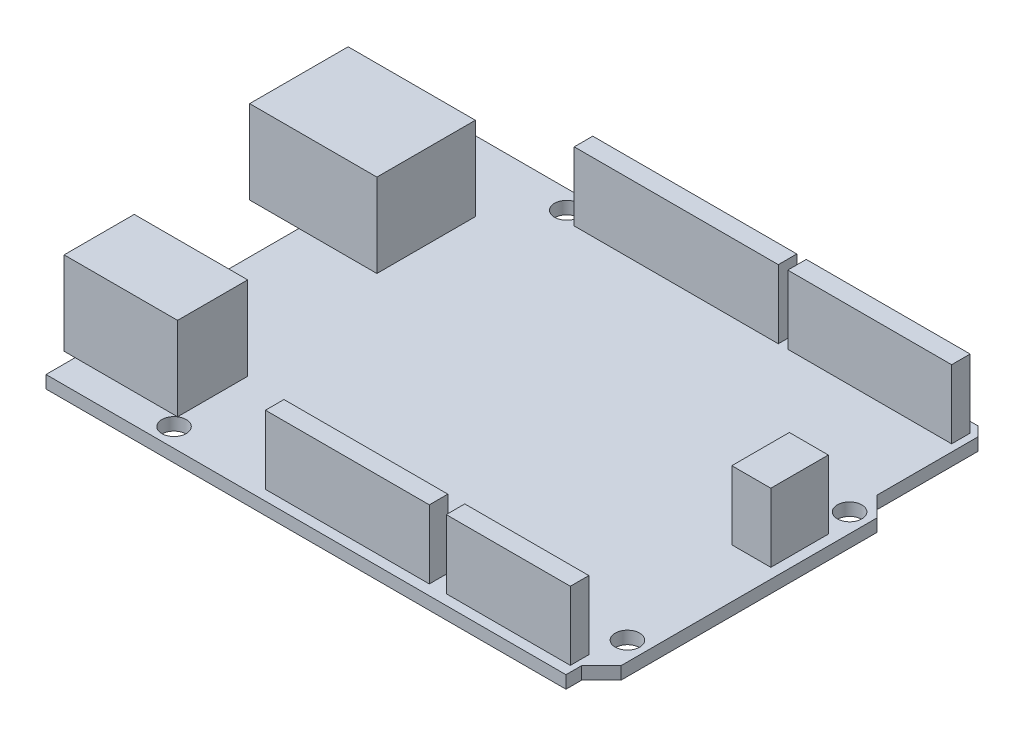
from build123d import *

# Parameters (mm, degrees)
SKETCH1_R           = 1.55
BOSS_EXTRUDE1_DEPTH = 1.6
SKETCH2_W           = 25.9
SKETCH2_H           = 2.35
SKETCH2_W_2         = 20.8
SKETCH2_W_3         = 15.75
SKETCH2_W_4         = 4.95
SKETCH2_H_2         = 7.3
BOSS_EXTRUDE2_DEPTH = 8.7
SKETCH3_W           = 16.15
SKETCH3_H           = 12.5
SKETCH3_W_2         = 14.4
SKETCH3_H_2         = 8.9
BOSS_EXTRUDE3_DEPTH = 10.6


with BuildPart() as part:
    # Sketch1 → Boss-Extrude1 (new body)
    with BuildSketch(Plane(origin=(0, 0, 0), x_dir=(1, 0, 0), z_dir=(0, 1, 0))):
        Polygon((66, 52.297918472), (66, 39.5), (68.5, 37), (68.5, 4.5), (66, 2), (66, 0), (0, 0), (0, 53.5), (64.797918472, 53.5), align=None)
        with Locations((15, 51.1)):
            Circle(SKETCH1_R, mode=Mode.SUBTRACT)
        with Locations((66.1, 35.9)):
            Circle(SKETCH1_R, mode=Mode.SUBTRACT)
        with Locations((66.1, 7.7)):
            Circle(SKETCH1_R, mode=Mode.SUBTRACT)
        with Locations((13.85, 2.4)):
            Circle(SKETCH1_R, mode=Mode.SUBTRACT)
    extrude(amount=BOSS_EXTRUDE1_DEPTH)

    # Sketch2 → Boss-Extrude2 (add)
    with BuildSketch(Plane(origin=(0, 1.6, 0), x_dir=(1, 0, 0), z_dir=(0, 1, 0))):
        with Locations((30.15, 51.025)):
            Rectangle(SKETCH2_W, SKETCH2_H)
        with Locations((54.7, 51.025)):
            Rectangle(SKETCH2_W_2, SKETCH2_H)
        with Locations((57.378669226, 2.475)):
            Rectangle(SKETCH2_W_3, SKETCH2_H)
        with Locations((36.953669226, 2.475)):
            Rectangle(SKETCH2_W_2, SKETCH2_H)
        with Locations((64.725, 28.45)):
            Rectangle(SKETCH2_W_4, SKETCH2_H_2)
    extrude(amount=BOSS_EXTRUDE2_DEPTH)

    # Sketch3 → Boss-Extrude3 (add)
    with BuildSketch(Plane(origin=(0, 1.6, 0), x_dir=(1, 0, 0), z_dir=(0, 1, 0))):
        with Locations((1.825, 38.35)):
            Rectangle(SKETCH3_W, SKETCH3_H)
        with Locations((5.8, 8.15)):
            Rectangle(SKETCH3_W_2, SKETCH3_H_2)
    extrude(amount=BOSS_EXTRUDE3_DEPTH)


solid = part.part
